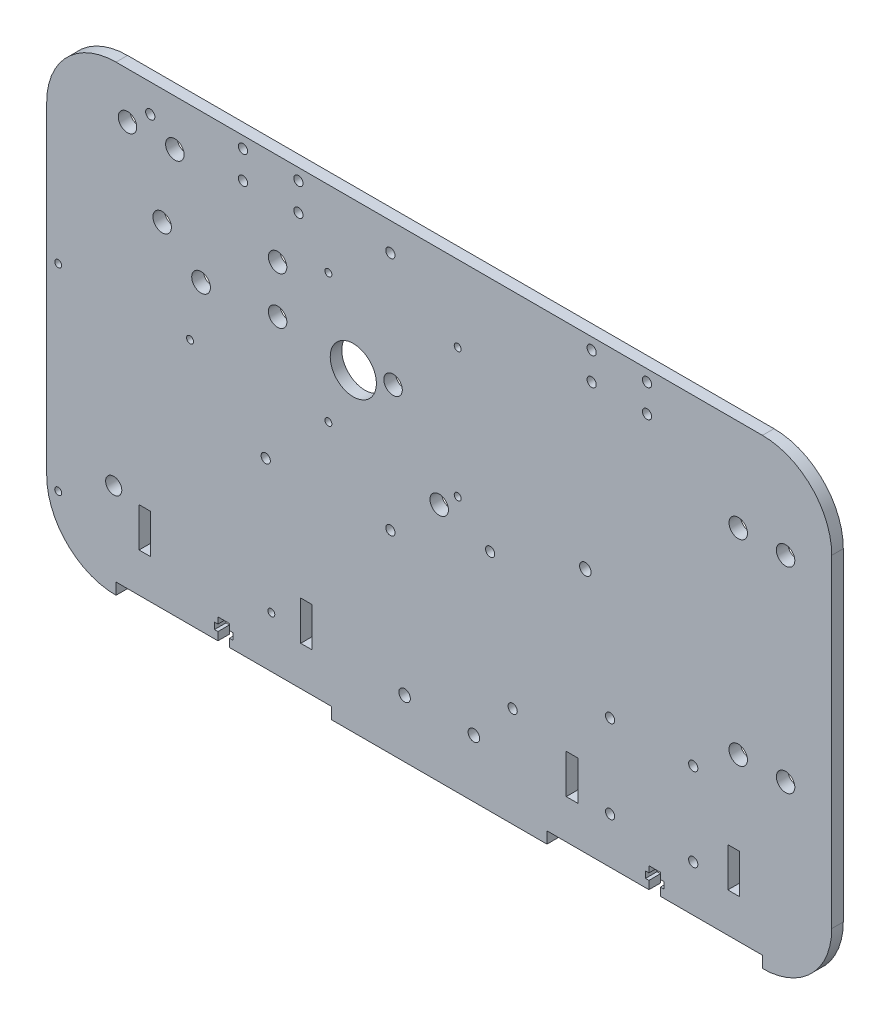
from build123d import *

# Parameters (mm, degrees)
SALIENTE_EXTRUIR1_DEPTH = 5
CROQUIS2_R              = 4
CORTAR_EXTRUIR4_DEPTH   = 10
CROQUIS3_R              = 2
CROQUIS3_R_2            = 10
CROQUIS3_R_3            = 4.05
CORTAR_EXTRUIR5_DEPTH   = 10
CROQUIS5_R              = 1.5
CORTAR_EXTRUIR6_DEPTH   = 10
CROQUIS6_R              = 2
CORTAR_EXTRUIR7_DEPTH   = 10
CROQUIS8_R              = 2
CORTAR_EXTRUIR8_DEPTH   = 10
CROQUIS9_R              = 3.5
CROQUIS9_R_2            = 1.5
CROQUIS9_R_3            = 2.5
CROQUIS9_R_4            = 2
CORTAR_EXTRUIR9_DEPTH   = 10
CROQUIS10_W             = 93.333333333
CROQUIS10_H             = 5
CORTAR_EXTRUIR10_DEPTH  = 10
CORTAR_EXTRUIR14_DEPTH  = 5
CROQUIS13_W             = 5
CROQUIS13_H             = 17
CORTAR_EXTRUIR15_DEPTH  = 5
CROQUIS14_R             = 2.5
CORTAR_EXTRUIR16_DEPTH  = 10


with BuildPart() as part:
    # Croquis1 → Saliente-Extruir1 (new body)
    with BuildSketch(Plane.XY):
        with BuildLine():
            Line((30, 0), (310, 0))
            ThreePointArc((310, 0), (331.213203436, 8.786796564), (340, 30))
            Line((340, 30), (340, 170))
            ThreePointArc((340, 170), (331.213203436, 191.213203436), (310, 200))
            Line((310, 200), (30, 200))
            ThreePointArc((30, 200), (8.786796564, 191.213203436), (0, 170))
            Line((0, 170), (0, 30))
            ThreePointArc((0, 30), (8.786796564, 8.786796564), (30, 0))
        make_face()
    extrude(amount=SALIENTE_EXTRUIR1_DEPTH)

    # Croquis2 → Cortar-Extruir4 (cut)
    with BuildSketch(Plane(origin=(0, 0, 5), x_dir=(-1, 0, 0), z_dir=(0, 0, -1))):
        with Locations((-55.5, 180)):
            Circle(CROQUIS2_R)
        with Locations((-35, 180)):
            Circle(CROQUIS2_R)
        with Locations((-100, 160)):
            Circle(CROQUIS2_R)
        with Locations((-100, 139.5)):
            Circle(CROQUIS2_R)
        with Locations((-299.5, 160)):
            Circle(CROQUIS2_R)
        with Locations((-320, 160)):
            Circle(CROQUIS2_R)
        with Locations((-320, 75)):
            Circle(CROQUIS2_R)
        with Locations((-299.5, 75)):
            Circle(CROQUIS2_R)
        with Locations((-150, 139)):
            Circle(CROQUIS2_R)
        with Locations((-170, 104)):
            Circle(CROQUIS2_R)
        with Locations((-50, 150)):
            Circle(CROQUIS2_R)
    extrude(amount=CORTAR_EXTRUIR4_DEPTH, mode=Mode.SUBTRACT)

    # Croquis3 → Cortar-Extruir5 (cut)
    with BuildSketch(Plane(origin=(0, 0, 0), x_dir=(-1, 0, 0), z_dir=(0, 0, -1))):
        with Locations((-148.85, 83.84)):
            Circle(CROQUIS3_R)
        with Locations((-94.85, 83.84)):
            Circle(CROQUIS3_R)
        with Locations((-44.85, 187.84)):
            Circle(CROQUIS3_R)
        with Locations((-148.85, 187.84)):
            Circle(CROQUIS3_R)
        with Locations((-132.79, 135.84)):
            Circle(CROQUIS3_R_2)
        with Locations((-66.85, 135.84)):
            Circle(CROQUIS3_R_3)
    extrude(amount=-CORTAR_EXTRUIR5_DEPTH, mode=Mode.SUBTRACT)

    # Croquis5 → Cortar-Extruir6 (cut)
    with BuildSketch(Plane(origin=(0, 0, 0), x_dir=(-1, 0, 0), z_dir=(0, 0, -1))):
        with Locations((-178, 167)):
            Circle(CROQUIS5_R)
        with Locations((-122, 111)):
            Circle(CROQUIS5_R)
        with Locations((-122, 167)):
            Circle(CROQUIS5_R)
        with Locations((-178, 111)):
            Circle(CROQUIS5_R)
    extrude(amount=-CORTAR_EXTRUIR6_DEPTH, mode=Mode.SUBTRACT)

    # Croquis6 → Cortar-Extruir7 (cut)
    with BuildSketch(Plane.XY.offset(5)):
        with Locations((244, 61)):
            Circle(CROQUIS6_R)
        with Locations((280, 61)):
            Circle(CROQUIS6_R)
        with Locations((244, 25)):
            Circle(CROQUIS6_R)
        with Locations((280, 25)):
            Circle(CROQUIS6_R)
    extrude(amount=-CORTAR_EXTRUIR7_DEPTH, mode=Mode.SUBTRACT)

    # Croquis8 → Cortar-Extruir8 (cut)
    with BuildSketch(Plane.XY.offset(5)):
        with Locations((236, 195)):
            Circle(CROQUIS8_R)
        with Locations((236, 183)):
            Circle(CROQUIS8_R)
        with Locations((260, 183)):
            Circle(CROQUIS8_R)
        with Locations((260, 195)):
            Circle(CROQUIS8_R)
        with Locations((85, 195)):
            Circle(CROQUIS8_R)
        with Locations((85, 183)):
            Circle(CROQUIS8_R)
        with Locations((109, 183)):
            Circle(CROQUIS8_R)
        with Locations((109, 195)):
            Circle(CROQUIS8_R)
    extrude(amount=-CORTAR_EXTRUIR8_DEPTH, mode=Mode.SUBTRACT)

    # Croquis9 → Cortar-Extruir9 (cut)
    with BuildSketch(Plane(origin=(0, 0, 0), x_dir=(-1, 0, 0), z_dir=(0, 0, -1))):
        with Locations((-29.01, 40.656502357)):
            Circle(CROQUIS9_R)
        with Locations((-62.080404779, 111.910005093)):
            Circle(CROQUIS9_R_2)
        with Locations((-4.98, 111.910005093)):
            Circle(CROQUIS9_R_2)
        with Locations((-97.280894834, 27.160005093)):
            Circle(CROQUIS9_R_2)
        with Locations((-4.98, 26.56)):
            Circle(CROQUIS9_R_2)
        with Locations((-233.296749654, 111.494889841)):
            Circle(CROQUIS9_R_3)
        with Locations((-201.8, 43.4)):
            Circle(CROQUIS9_R_4)
        with Locations((-192.05, 97.413240345)):
            Circle(CROQUIS9_R_4)
    extrude(amount=-CORTAR_EXTRUIR9_DEPTH, mode=Mode.SUBTRACT)

    # Croquis10 → Cortar-Extruir10 (cut)
    with BuildSketch(Plane.XY.offset(5)):
        with Locations((76.666666667, 2.5)):
            Rectangle(CROQUIS10_W, CROQUIS10_H)
        with Locations((263.333333334, 2.5)):
            Rectangle(CROQUIS10_W, CROQUIS10_H)
    extrude(amount=-CORTAR_EXTRUIR10_DEPTH, mode=Mode.SUBTRACT)

    # Croquis12 → Cortar-Extruir14 (cut)
    with BuildSketch(Plane.XY.offset(5)):
        Polygon((74.166666667, 5), (74.166666667, 8.5), (72.666666667, 8.5), (72.666666667, 11.3), (74.166666667, 11.3), (74.166666667, 14), (79.166666667, 14), (79.166666667, 11.3), (80.666666667, 11.3), (80.666666667, 8.5), (79.166666667, 8.5), (79.166666667, 5), align=None)
        Polygon((260.833333333, 11.3), (260.833333333, 14), (265.833333333, 14), (265.833333333, 11.3), (267.333333333, 11.3), (267.333333333, 8.5), (265.833333333, 8.5), (265.833333333, 5), (260.833333333, 5), (260.833333333, 8.5), (259.333333333, 8.5), (259.333333333, 11.3), align=None)
    extrude(amount=-CORTAR_EXTRUIR14_DEPTH, mode=Mode.SUBTRACT)

    # Croquis13 → Cortar-Extruir15 (cut)
    with BuildSketch(Plane.XY.offset(5)):
        with Locations((42.5, 30.5)):
            Rectangle(CROQUIS13_W, CROQUIS13_H)
        with Locations((112.5, 30.5)):
            Rectangle(CROQUIS13_W, CROQUIS13_H)
        with Locations((227.5, 30.5)):
            Rectangle(CROQUIS13_W, CROQUIS13_H)
        with Locations((297.5, 30.5)):
            Rectangle(CROQUIS13_W, CROQUIS13_H)
    extrude(amount=-CORTAR_EXTRUIR15_DEPTH, mode=Mode.SUBTRACT)

    # Croquis14 → Cortar-Extruir16 (cut)
    with BuildSketch(Plane.XY.offset(5)):
        with Locations((155, 25)):
            Circle(CROQUIS14_R)
        with Locations((185, 25)):
            Circle(CROQUIS14_R)
    extrude(amount=-CORTAR_EXTRUIR16_DEPTH, mode=Mode.SUBTRACT)


solid = part.part
